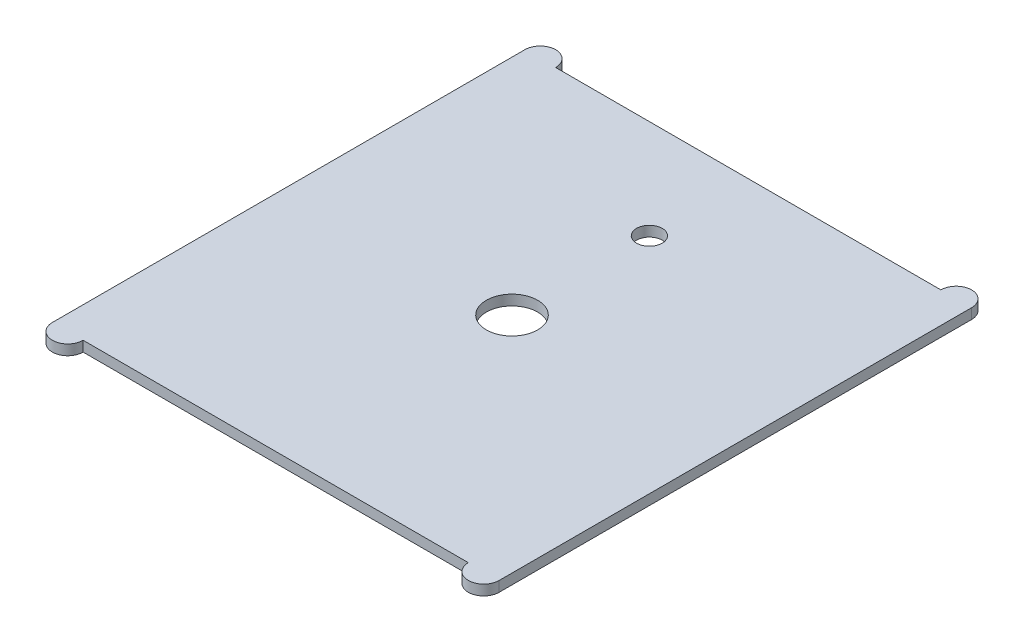
from build123d import *

# Parameters (mm, degrees)
SKETCH1_R           = 25
BOSS_EXTRUDE2_DEPTH = 10
SKETCH3_R           = 12.5
CUT_EXTRUDE3_DEPTH  = 11


with BuildPart() as part:
    # Sketch1 → Boss-Extrude2 (new body)
    with BuildSketch(Plane(origin=(0, 0, 0), x_dir=(1, 0, 0), z_dir=(0, 1, 0))):
        with BuildLine():
            Line((-187.5, 230), (187.5, 230))
            ThreePointArc((187.5, 230), (202.5, 245), (217.5, 230))
            Line((217.5, 230), (217.5, -230))
            ThreePointArc((217.5, -230), (202.5, -245), (187.5, -230))
            Line((187.5, -230), (-187.5, -230))
            ThreePointArc((-187.5, -230), (-202.5, -245), (-217.5, -230))
            Line((-217.5, -230), (-217.5, 230))
            ThreePointArc((-217.5, 230), (-202.5, 245), (-187.5, 230))
        make_face()
        Circle(SKETCH1_R, mode=Mode.SUBTRACT)
    extrude(amount=-BOSS_EXTRUDE2_DEPTH)

    # Sketch3 → Cut-Extrude3 (cut, through all)
    with BuildSketch(Plane(origin=(0, 0, 0), x_dir=(1, 0, 0), z_dir=(0, 1, 0))):
        with Locations((0, 133.75)):
            Circle(SKETCH3_R)
    extrude(amount=-CUT_EXTRUDE3_DEPTH, mode=Mode.SUBTRACT)


solid = part.part
